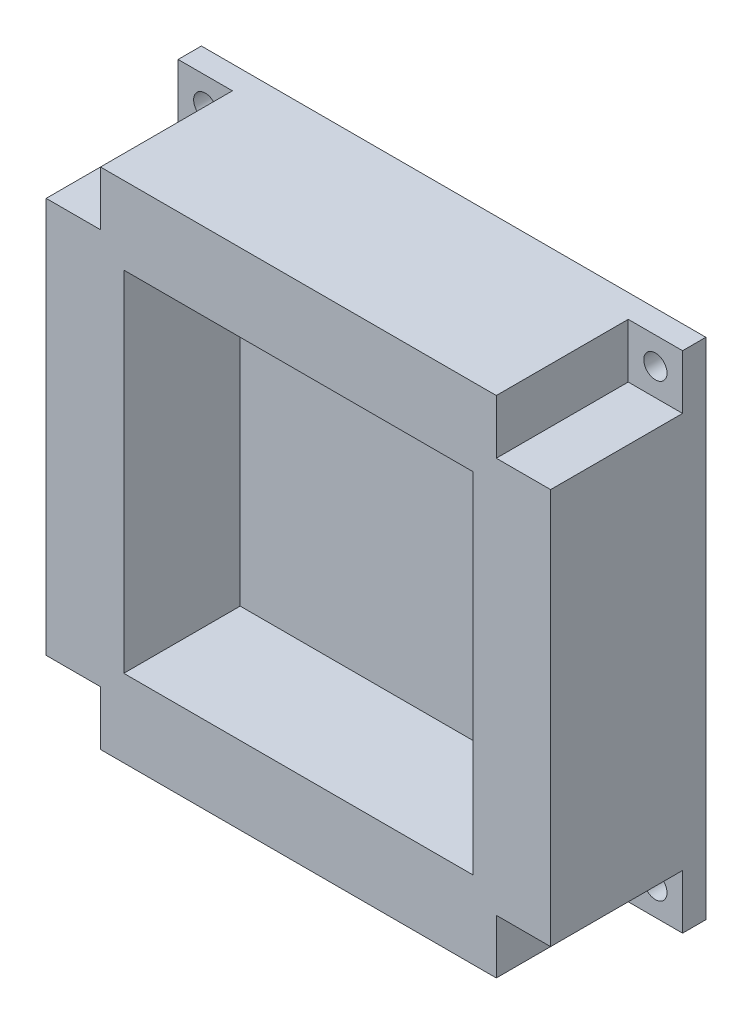
from build123d import *

# Parameters (mm, degrees)
SKETCH_1_W               = 65
SKETCH_1_H               = 65
EXTRUDE_4_DEPTH          = 20
SKETCH_3_W               = 45
SKETCH_3_H               = 45
CUT_EXTRUDE_1_DEPTH      = 15
SKETCH_4_W               = 7
SKETCH_4_H               = 7
CUT_EXTRUDE_2_DEPTH      = 17
PATTERN_CIRCULAR_1_COUNT = 4
SKETCH_5_R               = 1.5
CUT_EXTRUDE_3_DEPTH      = 3
PATTERN_CIRCULAR_2_COUNT = 4


with BuildPart() as part:
    # Эскиз1 → Бобышка-Вытянуть4 (new body)
    with BuildSketch(Plane.XY):
        Rectangle(SKETCH_1_W, SKETCH_1_H)
    extrude(amount=EXTRUDE_4_DEPTH)

    # Эскиз3 → Вырез-Вытянуть1 (cut)
    with BuildSketch(Plane.XY.offset(20)):
        Rectangle(SKETCH_3_W, SKETCH_3_H)
    extrude(amount=-CUT_EXTRUDE_1_DEPTH, mode=Mode.SUBTRACT)

    # Эскиз4 → Вырез-Вытянуть2 (cut)
    with BuildSketch(Plane.XY.offset(20)):
        with Locations((-29, 29)):
            Rectangle(SKETCH_4_W, SKETCH_4_H)
    cut_extrude_2 = extrude(amount=-CUT_EXTRUDE_2_DEPTH, mode=Mode.SUBTRACT)

    # Круговой массив1: Вырез-Вытянуть2 ×4 about axis
    pattern_circular_1_axis = Axis((0, 0, 0), (0, 0, 1))
    for i in range(1, PATTERN_CIRCULAR_1_COUNT):
        add(cut_extrude_2.rotate(pattern_circular_1_axis, i * 360 / PATTERN_CIRCULAR_1_COUNT), mode=Mode.SUBTRACT)

    # Эскиз5 → Вырез-Вытянуть3 (cut)
    with BuildSketch(Plane.XY.offset(3)):
        with Locations((-29, 29)):
            Circle(SKETCH_5_R)
    cut_extrude_3 = extrude(amount=-CUT_EXTRUDE_3_DEPTH, mode=Mode.SUBTRACT)

    # Круговой массив2: Вырез-Вытянуть3 ×4 about axis
    pattern_circular_2_axis = Axis((0, 0, 0), (0, 0, 1))
    for i in range(1, PATTERN_CIRCULAR_2_COUNT):
        add(cut_extrude_3.rotate(pattern_circular_2_axis, i * 360 / PATTERN_CIRCULAR_2_COUNT), mode=Mode.SUBTRACT)


solid = part.part
